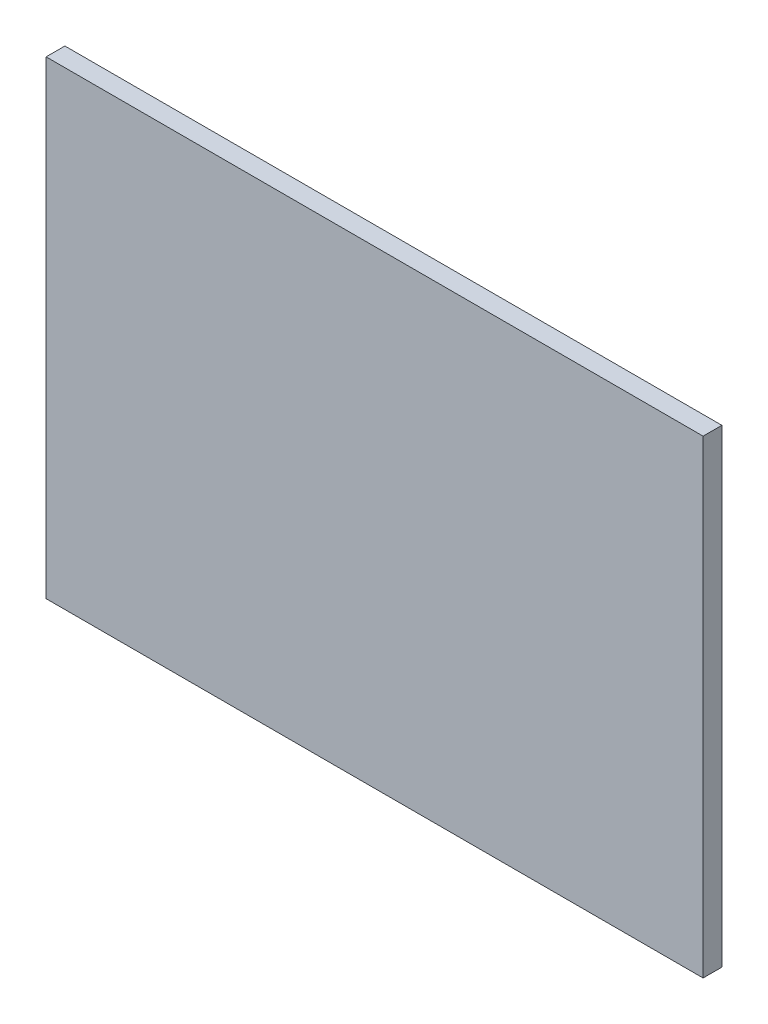
from build123d import *

# Parameters (mm, degrees)
SKIZZE1_W                       = 70
SKIZZE1_H                       = 50
AUFSATZ_LINEAR_AUSTRAGEN1_DEPTH = 2


with BuildPart() as part:
    # Skizze1 → Aufsatz-Linear austragen1 (new body)
    with BuildSketch(Plane.XY):
        with Locations((35, 25)):
            Rectangle(SKIZZE1_W, SKIZZE1_H)
    extrude(amount=AUFSATZ_LINEAR_AUSTRAGEN1_DEPTH)


solid = part.part
